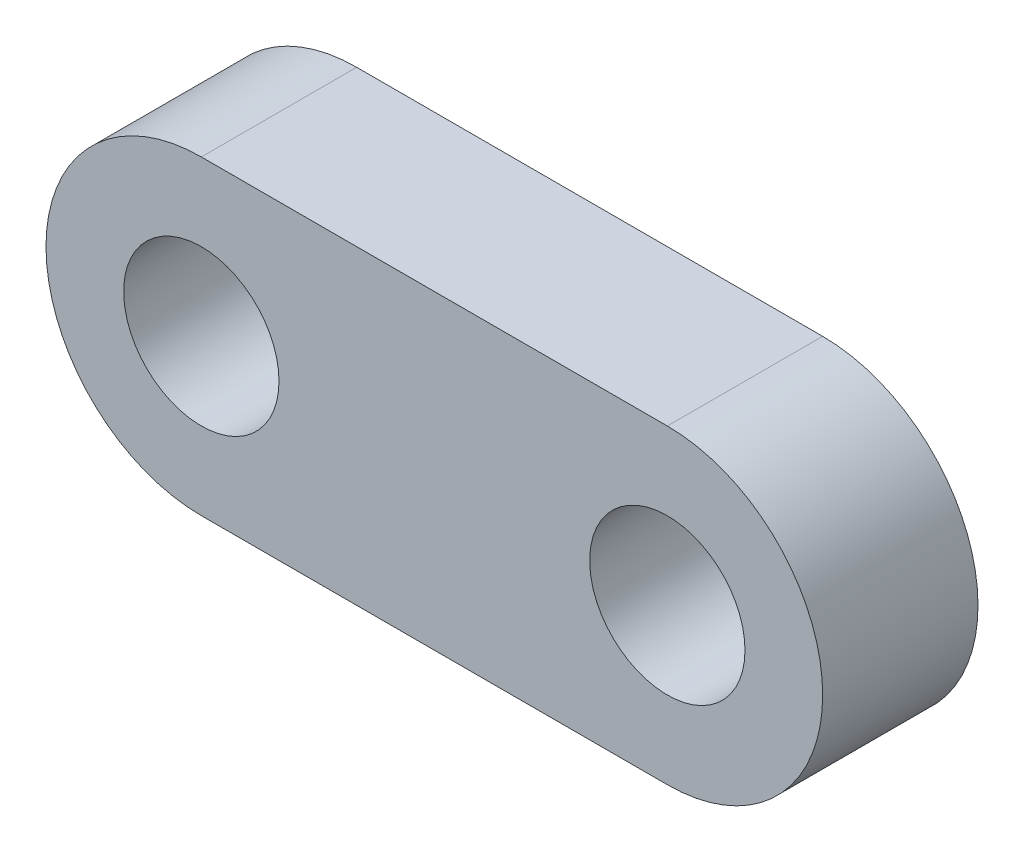
from build123d import *

# Parameters (mm, degrees)
SKETCH1_R           = 3.175
BOSS_EXTRUDE1_DEPTH = 6.35


with BuildPart() as part:
    # Sketch1 → Boss-Extrude1 (new body)
    with BuildSketch(Plane.XY):
        with BuildLine():
            Line((0, 6.35), (19.05, 6.35))
            ThreePointArc((19.05, 6.35), (25.4, 0), (19.05, -6.35))
            Line((19.05, -6.35), (0, -6.35))
            ThreePointArc((0, -6.35), (-6.35, 0), (0, 6.35))
        make_face()
        with Locations((19.05, 0)):
            Circle(SKETCH1_R, mode=Mode.SUBTRACT)
        Circle(SKETCH1_R, mode=Mode.SUBTRACT)
    extrude(amount=BOSS_EXTRUDE1_DEPTH)


solid = part.part
